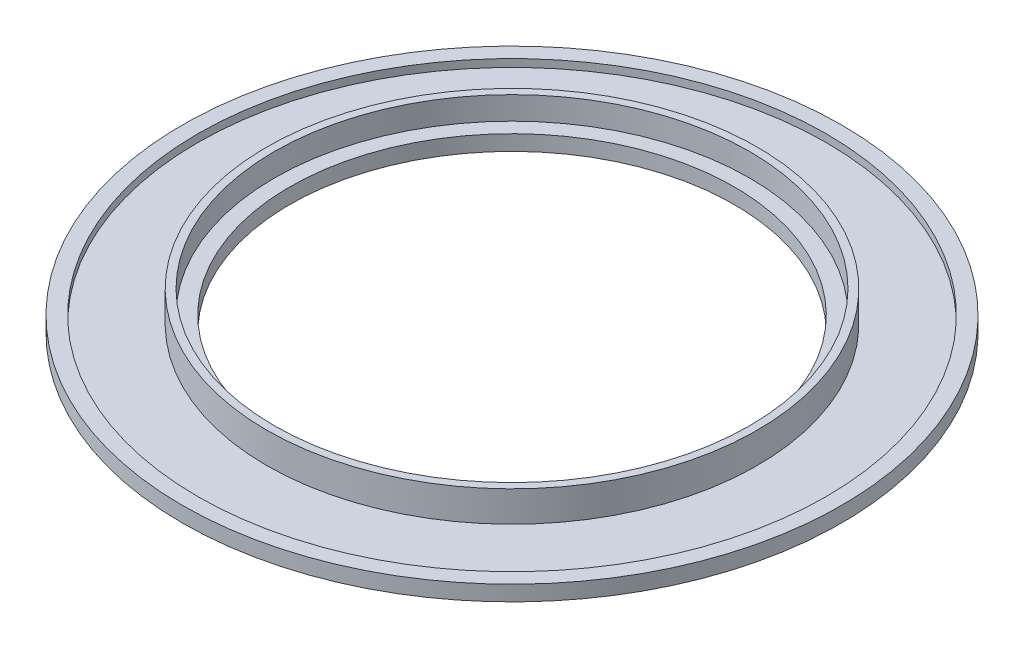
from build123d import *

# Parameters (mm, degrees)
SKETCH1_R           = 43
BOSS_EXTRUDE1_DEPTH = 2
SKETCH2_R           = 41
BOSS_EXTRUDE2_DEPTH = 3
SKETCH3_R           = 30
CUT_EXTRUDE1_DEPTH  = 2
SKETCH4_R           = 28
CUT_EXTRUDE2_DEPTH  = 4
SKETCH5_R           = 41
CUT_EXTRUDE3_DEPTH  = 4
SKETCH6_R           = 32
BOSS_EXTRUDE4_DEPTH = 4
SKETCH7_R           = 31
CUT_EXTRUDE4_DEPTH  = 3
SKETCH8_R           = 29
CUT_EXTRUDE5_DEPTH  = 3


with BuildPart() as part:
    # Sketch1 → Boss-Extrude1 (new body)
    with BuildSketch(Plane(origin=(0, 0, 0), x_dir=(1, 0, 0), z_dir=(0, 1, 0))):
        Circle(SKETCH1_R)
    extrude(amount=BOSS_EXTRUDE1_DEPTH)

    # Sketch2 → Boss-Extrude2 (add)
    with BuildSketch(Plane(origin=(0, 2, 0), x_dir=(1, 0, 0), z_dir=(0, 1, 0))):
        Circle(SKETCH2_R)
    extrude(amount=BOSS_EXTRUDE2_DEPTH)

    # Sketch3 → Cut-Extrude1 (cut)
    with BuildSketch(Plane(origin=(0, 5, 0), x_dir=(1, 0, 0), z_dir=(0, 1, 0))):
        Circle(SKETCH3_R)
    extrude(amount=-CUT_EXTRUDE1_DEPTH, mode=Mode.SUBTRACT)

    # Sketch4 → Cut-Extrude2 (cut, through all)
    with BuildSketch(Plane(origin=(0, 3, 0), x_dir=(1, 0, 0), z_dir=(0, 1, 0))):
        Circle(SKETCH4_R)
    extrude(amount=-CUT_EXTRUDE2_DEPTH, mode=Mode.SUBTRACT)

    # Sketch5 → Cut-Extrude3 (cut)
    with BuildSketch(Plane(origin=(0, 5, 0), x_dir=(1, 0, 0), z_dir=(0, 1, 0))):
        Circle(SKETCH5_R)
    extrude(amount=-CUT_EXTRUDE3_DEPTH, mode=Mode.SUBTRACT)

    # Sketch6 → Boss-Extrude4 (add)
    with BuildSketch(Plane(origin=(0, 1, 0), x_dir=(1, 0, 0), z_dir=(0, 1, 0))):
        Circle(SKETCH6_R)
    extrude(amount=BOSS_EXTRUDE4_DEPTH)

    # Sketch7 → Cut-Extrude4 (cut)
    with BuildSketch(Plane(origin=(0, 5, 0), x_dir=(1, 0, 0), z_dir=(0, 1, 0))):
        Circle(SKETCH7_R)
    extrude(amount=-CUT_EXTRUDE4_DEPTH, mode=Mode.SUBTRACT)

    # Sketch8 → Cut-Extrude5 (cut, through all)
    with BuildSketch(Plane(origin=(0, 2, 0), x_dir=(1, 0, 0), z_dir=(0, 1, 0))):
        Circle(SKETCH8_R)
    extrude(amount=-CUT_EXTRUDE5_DEPTH, mode=Mode.SUBTRACT)


solid = part.part
